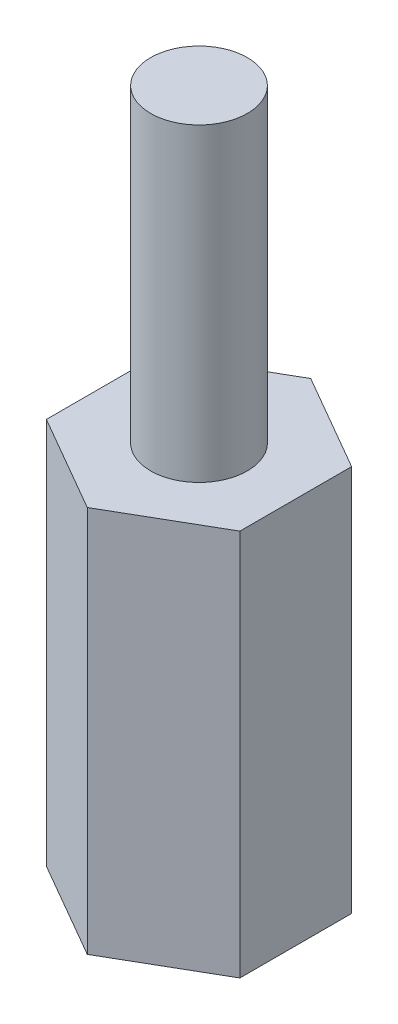
from build123d import *

# Parameters (mm, degrees)
BOSS_EXTRUDE1_DEPTH = 10
SKETCH2_R           = 1.25
BOSS_EXTRUDE2_DEPTH = 8
SKETCH3_R           = 1.25
CUT_EXTRUDE1_DEPTH  = 8


with BuildPart() as part:
    # Sketch1 → Boss-Extrude1 (new body)
    with BuildSketch(Plane(origin=(0, 0, 0), x_dir=(1, 0, 0), z_dir=(0, 1, 0))):
        Polygon((0, 2.886751346), (-2.5, 1.443375673), (-2.5, -1.443375673), (0, -2.886751346), (2.5, -1.443375673), (2.5, 1.443375673), align=None)
    extrude(amount=BOSS_EXTRUDE1_DEPTH)

    # Sketch2 → Boss-Extrude2 (add)
    with BuildSketch(Plane(origin=(0, 10, 0), x_dir=(1, 0, 0), z_dir=(0, 1, 0))):
        Circle(SKETCH2_R)
    extrude(amount=BOSS_EXTRUDE2_DEPTH)

    # Sketch3 → Cut-Extrude1 (cut)
    with BuildSketch(Plane(origin=(0, 0, 0), x_dir=(-1, 0, 0), z_dir=(0, -1, 0))):
        Circle(SKETCH3_R)
    extrude(amount=-CUT_EXTRUDE1_DEPTH, mode=Mode.SUBTRACT)


solid = part.part
